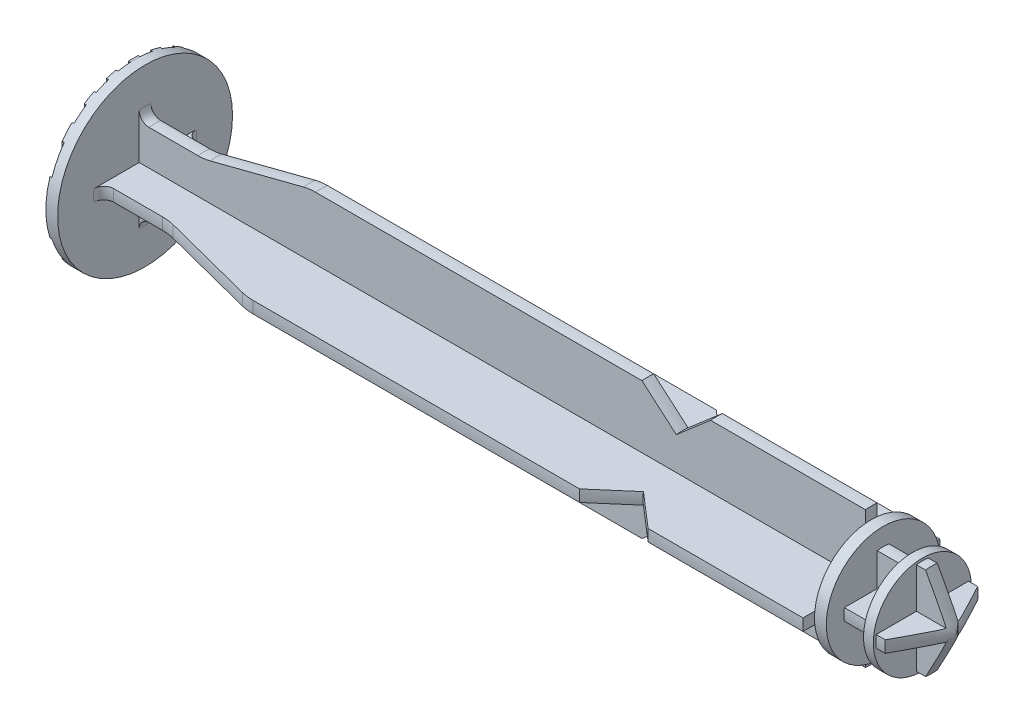
from build123d import *

# Parameters (mm, degrees)
SKETCH2_OUTSIDE_W   = 37.392
SKETCH2_OUTSIDE_H   = 37.392
CUT_EXTRUDE1_DEPTH  = 74.1
SKETCH3_OUTSIDE_W   = 37.392
SKETCH3_OUTSIDE_H   = 37.392
SKETCH3_OUTSIDE_W_2 = 1
SKETCH3_OUTSIDE_H_2 = 17.821966782
CUT_EXTRUDE2_DEPTH  = 0.2
SKETCH4_OUTSIDE_W   = 37.392
SKETCH4_OUTSIDE_H   = 37.392
CUT_EXTRUDE3_DEPTH  = 3
SKETCH5_OUTSIDE_W   = 37.392
SKETCH5_OUTSIDE_H   = 37.392
CUT_EXTRUDE4_DEPTH  = 3.5


with BuildPart() as part:
    # Sketch1 → Revolve1 (revolve)
    with BuildSketch(Plane.XY):
        with BuildLine():
            Line((0, 0), (0, 8.925))
            Line((0, 8.925), (1.2, 8.925))
            Line((1.2, 8.925), (1.2, 5.25))
            ThreePointArc((1.2, 5.25), (1.492893219, 4.542893219), (2.2, 4.25))
            Line((2.2, 4.25), (7.2, 4.25))
            ThreePointArc((7.2, 4.25), (7.825023292, 4.289219226), (8.440241411, 4.406261646))
            Line((8.440241411, 4.406261646), (17.959758589, 6.843738354))
            ThreePointArc((17.959758589, 6.843738354), (18.574976708, 6.960780774), (19.2, 7))
            Line((19.2, 7), (52.5, 7))
            Line((52.5, 7), (56, 4))
            Line((56, 4), (59.5, 7))
            Line((59.5, 7), (75.3, 7))
            Line((75.3, 7), (75.3, 5.8))
            Line((75.3, 5.8), (76.5, 5.8))
            Line((76.5, 5.8), (76.5, 4))
            Line((76.5, 4), (79.5, 4))
            Line((79.5, 4), (79.5, 5))
            Line((79.5, 5), (81.3, 5))
            Line((81.3, 5), (84, 0))
            Line((84, 0), (0, 0))
        make_face()
    revolve(axis=Axis((84, 0, 0), (-1, 0, 0)))

    # Sketch2 outside → Cut-Extrude1 (cut)
    with BuildSketch(Plane(origin=(1.2, 0, 0), x_dir=(0, 0, -1), z_dir=(1, 0, 0))):
        Rectangle(SKETCH2_OUTSIDE_W, SKETCH2_OUTSIDE_H)
        with BuildLine():
            Line((-0.6, 8.904809094), (-0.6, 0.6))
            Line((-0.6, 0.6), (-8.904809094, 0.6))
            ThreePointArc((-8.904809094, 0.6), (-8.925, 0), (-8.904809094, -0.6))
            Line((-8.904809094, -0.6), (-0.6, -0.6))
            Line((-0.6, -0.6), (-0.6, -8.904809094))
            ThreePointArc((-0.6, -8.904809094), (0, -8.925), (0.6, -8.904809094))
            Line((0.6, -8.904809094), (0.6, -0.6))
            Line((0.6, -0.6), (8.904809094, -0.6))
            ThreePointArc((8.904809094, -0.6), (8.925, 0), (8.904809094, 0.6))
            Line((8.904809094, 0.6), (0.6, 0.6))
            Line((0.6, 0.6), (0.6, 8.904809094))
            ThreePointArc((0.6, 8.904809094), (0, 8.925), (-0.6, 8.904809094))
        make_face(mode=Mode.SUBTRACT)
    extrude(amount=CUT_EXTRUDE1_DEPTH, mode=Mode.SUBTRACT)

    # Sketch3 outside → Cut-Extrude2 (cut)
    with BuildSketch(Plane.ZY):
        Rectangle(SKETCH3_OUTSIDE_W, SKETCH3_OUTSIDE_H)
        with Locations((2.25, 0)):
            Rectangle(SKETCH3_OUTSIDE_W_2, SKETCH3_OUTSIDE_H_2, mode=Mode.SUBTRACT)
        Rectangle(SKETCH3_OUTSIDE_W_2, SKETCH3_OUTSIDE_H_2, mode=Mode.SUBTRACT)
        with Locations((4.5, 0)):
            Rectangle(SKETCH3_OUTSIDE_W_2, SKETCH3_OUTSIDE_H_2, mode=Mode.SUBTRACT)
        with Locations((6.75, 0)):
            Rectangle(SKETCH3_OUTSIDE_W_2, SKETCH3_OUTSIDE_H_2, mode=Mode.SUBTRACT)
        with Locations((9, 0)):
            Rectangle(SKETCH3_OUTSIDE_W_2, SKETCH3_OUTSIDE_H_2, mode=Mode.SUBTRACT)
        with Locations((11.25, 0)):
            Rectangle(SKETCH3_OUTSIDE_W_2, SKETCH3_OUTSIDE_H_2, mode=Mode.SUBTRACT)
        with Locations((13.5, 0)):
            Rectangle(SKETCH3_OUTSIDE_W_2, SKETCH3_OUTSIDE_H_2, mode=Mode.SUBTRACT)
        with Locations((-2.25, 0)):
            Rectangle(SKETCH3_OUTSIDE_W_2, SKETCH3_OUTSIDE_H_2, mode=Mode.SUBTRACT)
        with Locations((-4.5, 0)):
            Rectangle(SKETCH3_OUTSIDE_W_2, SKETCH3_OUTSIDE_H_2, mode=Mode.SUBTRACT)
        with Locations((-6.75, 0)):
            Rectangle(SKETCH3_OUTSIDE_W_2, SKETCH3_OUTSIDE_H_2, mode=Mode.SUBTRACT)
        with Locations((-9, 0)):
            Rectangle(SKETCH3_OUTSIDE_W_2, SKETCH3_OUTSIDE_H_2, mode=Mode.SUBTRACT)
        with Locations((-11.25, 0)):
            Rectangle(SKETCH3_OUTSIDE_W_2, SKETCH3_OUTSIDE_H_2, mode=Mode.SUBTRACT)
        with Locations((-13.5, 0)):
            Rectangle(SKETCH3_OUTSIDE_W_2, SKETCH3_OUTSIDE_H_2, mode=Mode.SUBTRACT)
    extrude(amount=-CUT_EXTRUDE2_DEPTH, mode=Mode.SUBTRACT)

    # Sketch4 outside → Cut-Extrude3 (cut)
    with BuildSketch(Plane(origin=(76.5, 0, 0), x_dir=(0, 0, -1), z_dir=(1, 0, 0))):
        Rectangle(SKETCH4_OUTSIDE_W, SKETCH4_OUTSIDE_H)
        with BuildLine():
            Line((0.6, 0.6), (0.6, 8.904809094))
            ThreePointArc((0.6, 8.904809094), (0, 8.925), (-0.6, 8.904809094))
            Line((-0.6, 8.904809094), (-0.6, 0.6))
            Line((-0.6, 0.6), (-8.904809094, 0.6))
            ThreePointArc((-8.904809094, 0.6), (-8.925, 0), (-8.904809094, -0.6))
            Line((-8.904809094, -0.6), (-0.6, -0.6))
            Line((-0.6, -0.6), (-0.6, -8.904809094))
            ThreePointArc((-0.6, -8.904809094), (0, -8.925), (0.6, -8.904809094))
            Line((0.6, -8.904809094), (0.6, -0.6))
            Line((0.6, -0.6), (8.904809094, -0.6))
            ThreePointArc((8.904809094, -0.6), (8.925, 0), (8.904809094, 0.6))
            Line((8.904809094, 0.6), (0.6, 0.6))
        make_face(mode=Mode.SUBTRACT)
    extrude(amount=CUT_EXTRUDE3_DEPTH, mode=Mode.SUBTRACT)

    # Sketch5 outside → Cut-Extrude4 (cut)
    with BuildSketch(Plane(origin=(84, 0, 0), x_dir=(0, 0, -1), z_dir=(1, 0, 0))):
        Rectangle(SKETCH5_OUTSIDE_W, SKETCH5_OUTSIDE_H)
        with BuildLine():
            Line((0.6, 0.6), (0.6, 4.711952886))
            ThreePointArc((0.6, 4.711952886), (0, 4.75), (-0.6, 4.711952886))
            Line((-0.6, 4.711952886), (-0.6, 0.6))
            Line((-0.6, 0.6), (-4.711952886, 0.6))
            ThreePointArc((-4.711952886, 0.6), (-4.75, 0), (-4.711952886, -0.6))
            Line((-4.711952886, -0.6), (-0.6, -0.6))
            Line((-0.6, -0.6), (-0.6, -4.711952886))
            ThreePointArc((-0.6, -4.711952886), (0, -4.75), (0.6, -4.711952886))
            Line((0.6, -4.711952886), (0.6, -0.6))
            Line((0.6, -0.6), (4.711952886, -0.6))
            ThreePointArc((4.711952886, -0.6), (4.75, 0), (4.711952886, 0.6))
            Line((4.711952886, 0.6), (0.6, 0.6))
        make_face(mode=Mode.SUBTRACT)
    extrude(amount=-CUT_EXTRUDE4_DEPTH, mode=Mode.SUBTRACT)


solid = part.part
